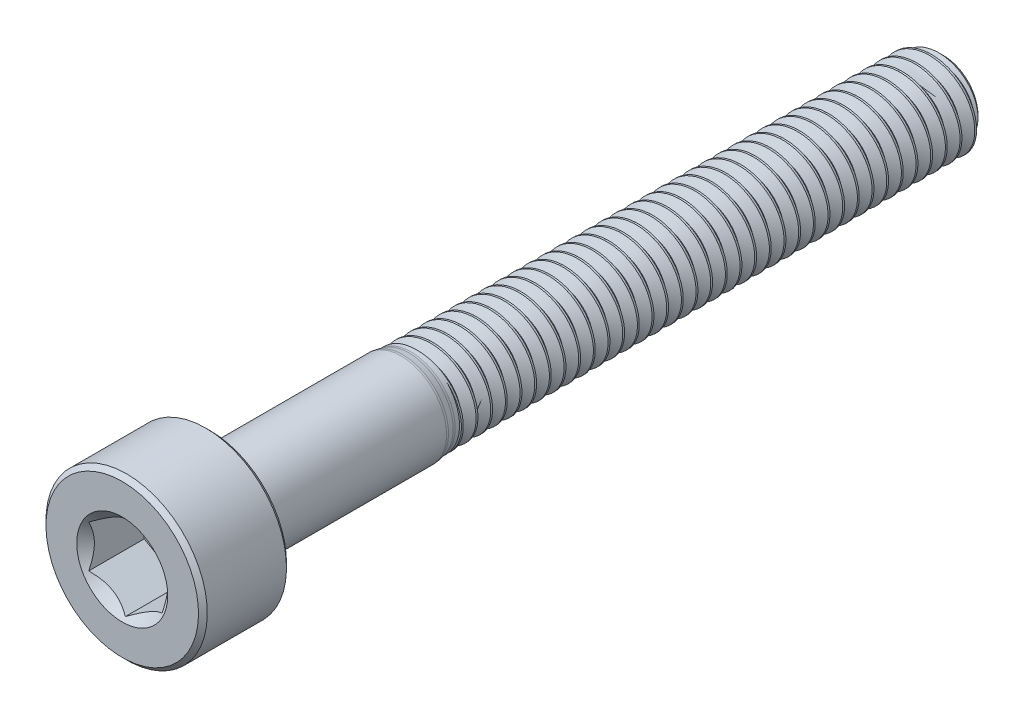
from build123d import *

# Parameters (mm, degrees)
CUT_EXTRUDE1_DEPTH     = 2
SKETCH4_R              = 1.551629
CUT_EXTRUDE2_DEPTH     = 1.5
CUT_EXTRUDE2_DRAFT     = -45
SPLIT1_SURFACE_1_BACK  = 30.06
SPLIT1_SURFACE_1_DEPTH = 60.12
SPLIT1_SURFACE_2_BACK  = 30.06
SPLIT1_SURFACE_2_DEPTH = 60.12
CUT_SWEEP1_PITCH       = 0.5
CUT_SWEEP1_HEIGHT      = 18.5
CUT_SWEEP1_RADIUS      = 1.5
CUT_SWEEP1_START_ANGLE = 90


with BuildPart() as part:
    # Sketch2 → Revolve1 (revolve)
    with BuildSketch(Plane(origin=(0, 0, 0), x_dir=(0, 0, -1), z_dir=(1, 0, 0))):
        with BuildLine():
            Line((-14, 0), (-14, 2.6))
            Line((-14, 2.6), (-13.85, 2.75))
            Line((-13.85, 2.75), (-11.15, 2.75))
            Line((-11.15, 2.75), (-11, 2.6))
            Line((-11, 2.6), (-11, 1.704127))
            ThreePointArc((-11, 1.704127), (-10.956066, 1.598061), (-10.85, 1.554127))
            Line((-10.85, 1.554127), (-4.496547, 1.554127))
            ThreePointArc((-4.496547, 1.554127), (-4.459791, 1.552321), (-4.423388, 1.546921))
            Line((-4.423388, 1.546921), (-4.223725, 1.507206))
            ThreePointArc((-4.223725, 1.507206), (-4.187322, 1.501806), (-4.150566, 1.5))
            Line((-4.150566, 1.5), (13.67524, 1.5))
            Line((13.67524, 1.5), (14, 1.17524))
            Line((14, 1.17524), (14, 0))
            Line((14, 0), (-14, 0))
        make_face()
    revolve(axis=Axis((0, 0, -14), (0, 0, 1)))

    # Sketch3 → Cut-Extrude1 (cut)
    with BuildSketch(Plane.XY.offset(14)):
        Polygon((1.25, -0.721688), (1.25, 0.721688), (0, 1.443376), (-1.25, 0.721688), (-1.25, -0.721688), (0, -1.443376), align=None)
    extrude(amount=-CUT_EXTRUDE1_DEPTH, mode=Mode.SUBTRACT)


with BuildPart() as cut_extrude2_tool:
    # Sketch4 → Cut-Extrude2 (with draft: the straight prism first)
    with BuildSketch(Plane.XY.offset(14)):
        Circle(SKETCH4_R)
    extrude(amount=-CUT_EXTRUDE2_DEPTH)
    # Cut-Extrude2: the draft: its side faces are tilted about the plane it starts from
    cut_extrude2_sides = [cut_extrude2_tool.faces().sort_by_distance(p)[0] for p in [
        (-1.551629, 0, 13.25),
    ]]
    draft(cut_extrude2_sides, Plane.XY.offset(14), CUT_EXTRUDE2_DRAFT)


with BuildPart() as part_1:
    add(part.part)

    # Cut-Extrude2: cut by cut_extrude2_tool
    add(cut_extrude2_tool.part, mode=Mode.SUBTRACT)


with BuildPart() as body_2:
    # Split1: the piece behind the surface
    add(part_1.part)
    # Split1 surface: a surface, the sketch's curves swept straight by 60.12 mm
    with BuildLine(Plane(origin=(0, 0, 0), x_dir=(0, 0, -1), z_dir=(1, 0, 0)).offset(-SPLIT1_SURFACE_1_BACK), mode=Mode.PRIVATE) as split1_surface_1_path:
        Line((-4, -1.5), (-4, 1.5))
    split1_surface_1 = Shell.extrude(split1_surface_1_path.wire(), (1 * SPLIT1_SURFACE_1_DEPTH, 0 * SPLIT1_SURFACE_1_DEPTH, 0 * SPLIT1_SURFACE_1_DEPTH))
    split(bisect_by=split1_surface_1, keep=Keep.BOTTOM)

    # Cut-Sweep1: sweep along a helix
    with BuildLine() as cut_sweep1_path:
        add(Helix(CUT_SWEEP1_PITCH, CUT_SWEEP1_HEIGHT, CUT_SWEEP1_RADIUS, center=(0, 0, -14), direction=(0, 0, 1), mode=Mode.PRIVATE).rotate(Axis((0, 0, -14), (0, 0, 1)), CUT_SWEEP1_START_ANGLE))
    # Sketch7 → Cut-Sweep1 (sweep, cut)
    with BuildSketch(Plane(origin=(0, 0, 0), x_dir=(0, 0, -1), z_dir=(1, 0, 0))):
        Polygon((13.984375, 1.527063), (14.453125, 1.527063), (14.25, 1.17524), (14.1875, 1.17524), align=None)
    sweep(path=cut_sweep1_path.line, is_frenet=True, mode=Mode.SUBTRACT)


with BuildPart() as part_2:
    add(part_1.part)

    # Split1: split by a surface, the side it looks to stays
    # Split1 surface: a surface, the sketch's curves swept straight by 60.12 mm
    with BuildLine(Plane(origin=(0, 0, 0), x_dir=(0, 0, -1), z_dir=(1, 0, 0)).offset(-SPLIT1_SURFACE_2_BACK), mode=Mode.PRIVATE) as split1_surface_2_path:
        Line((-4, -1.5), (-4, 1.5))
    split1_surface_2 = Shell.extrude(split1_surface_2_path.wire(), (1 * SPLIT1_SURFACE_2_DEPTH, 0 * SPLIT1_SURFACE_2_DEPTH, 0 * SPLIT1_SURFACE_2_DEPTH))
    split(bisect_by=split1_surface_2, keep=Keep.TOP)

    add(body_2.part)  # Revolve2 merges body 2
    # Sketch8 → Revolve2 (revolve)
    with BuildSketch(Plane(origin=(0, 0, 0), x_dir=(0, 0, -1), z_dir=(1, 0, 0))):
        Polygon((-11, 0), (-11, 1.5), (-4, 1.5), (-3.133975, 0), align=None)
    revolve(axis=Axis((0, 0, 3.133975), (0, 0, 1)))


solid = part_2.part
